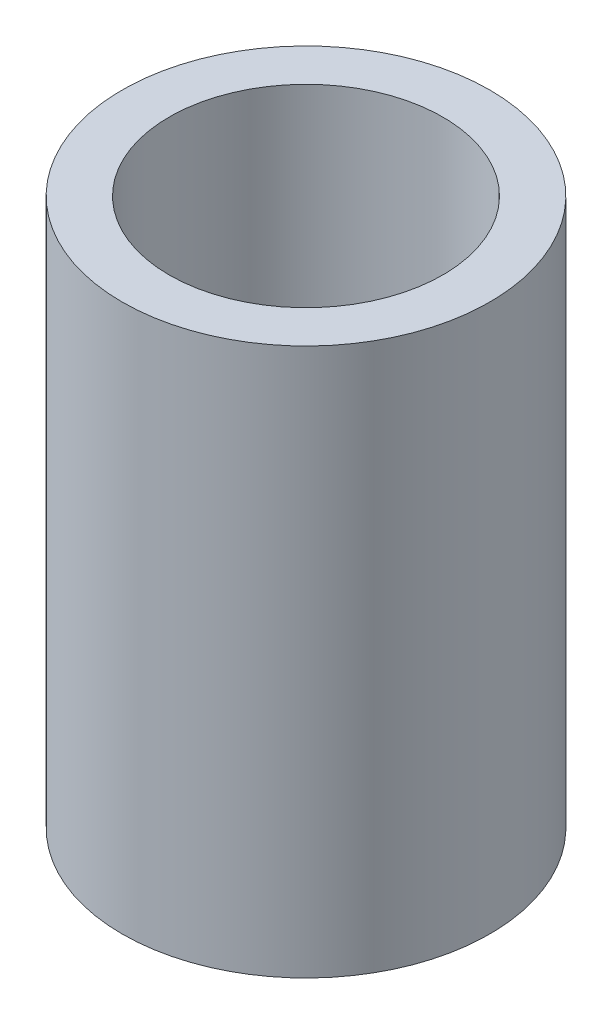
from build123d import *

# Parameters (mm, degrees)
SKETCH1_R           = 4.7
SKETCH1_R_2         = 3.5
BOSS_EXTRUDE1_DEPTH = 14


with BuildPart() as part:
    # Sketch1 → Boss-Extrude1 (new body)
    with BuildSketch(Plane(origin=(0, 0, 0), x_dir=(1, 0, 0), z_dir=(0, 1, 0))):
        Circle(SKETCH1_R)
        Circle(SKETCH1_R_2, mode=Mode.SUBTRACT)
    extrude(amount=BOSS_EXTRUDE1_DEPTH)


solid = part.part
